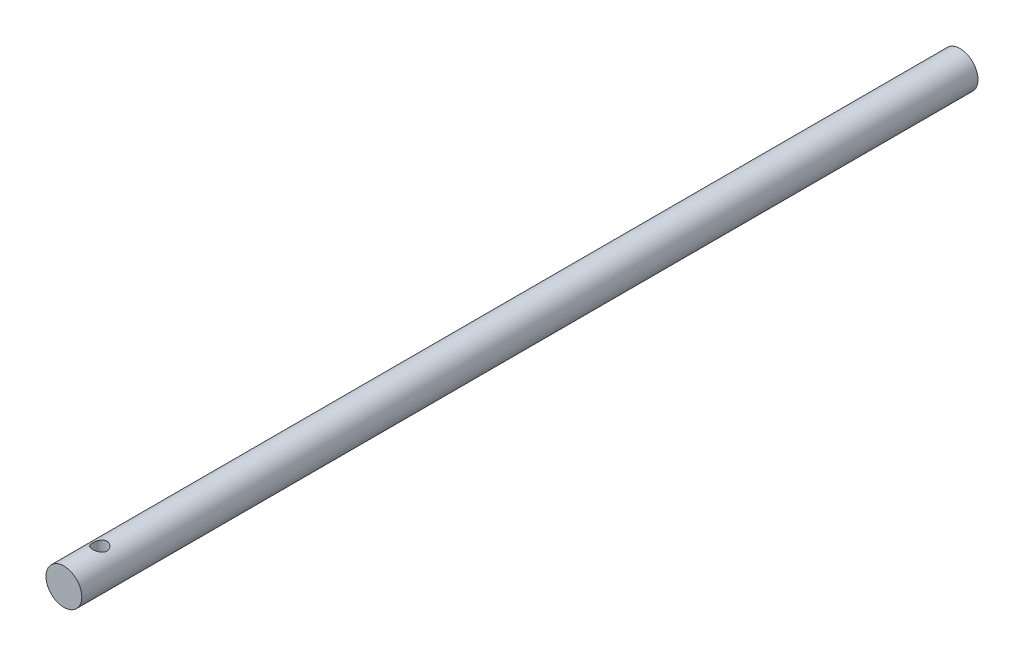
from build123d import *

# Parameters (mm, degrees)
ESQUISSE1_R             = 0.5
BOSS_EXTRU_1_DEPTH      = 25
ESQUISSE3_R             = 0.2
ENL_V_MAT_EXTRU_3_DEPTH = 1
ESQUISSE4_R             = 0.2
ENL_V_MAT_EXTRU_4_DEPTH = 1


with BuildPart() as part:
    # Esquisse1 → Boss.-Extru.1 (new body)
    with BuildSketch(Plane.XY):
        Circle(ESQUISSE1_R)
    extrude(amount=BOSS_EXTRU_1_DEPTH)

    # Esquisse3 → Enlèv. mat.-Extru.3 (cut)
    with BuildSketch(Plane(origin=(0, 0, 0), x_dir=(1, 0, 0), z_dir=(0, 1, 0))):
        with Locations((0, -1)):
            Circle(ESQUISSE3_R)
    extrude(amount=-ENL_V_MAT_EXTRU_3_DEPTH, mode=Mode.SUBTRACT)

    # Esquisse4 → Enlèv. mat.-Extru.4 (cut)
    with BuildSketch(Plane(origin=(0, 0, 0), x_dir=(1, 0, 0), z_dir=(0, 1, 0))):
        with Locations((0, -24)):
            Circle(ESQUISSE4_R)
    extrude(amount=ENL_V_MAT_EXTRU_4_DEPTH, mode=Mode.SUBTRACT)


solid = part.part
